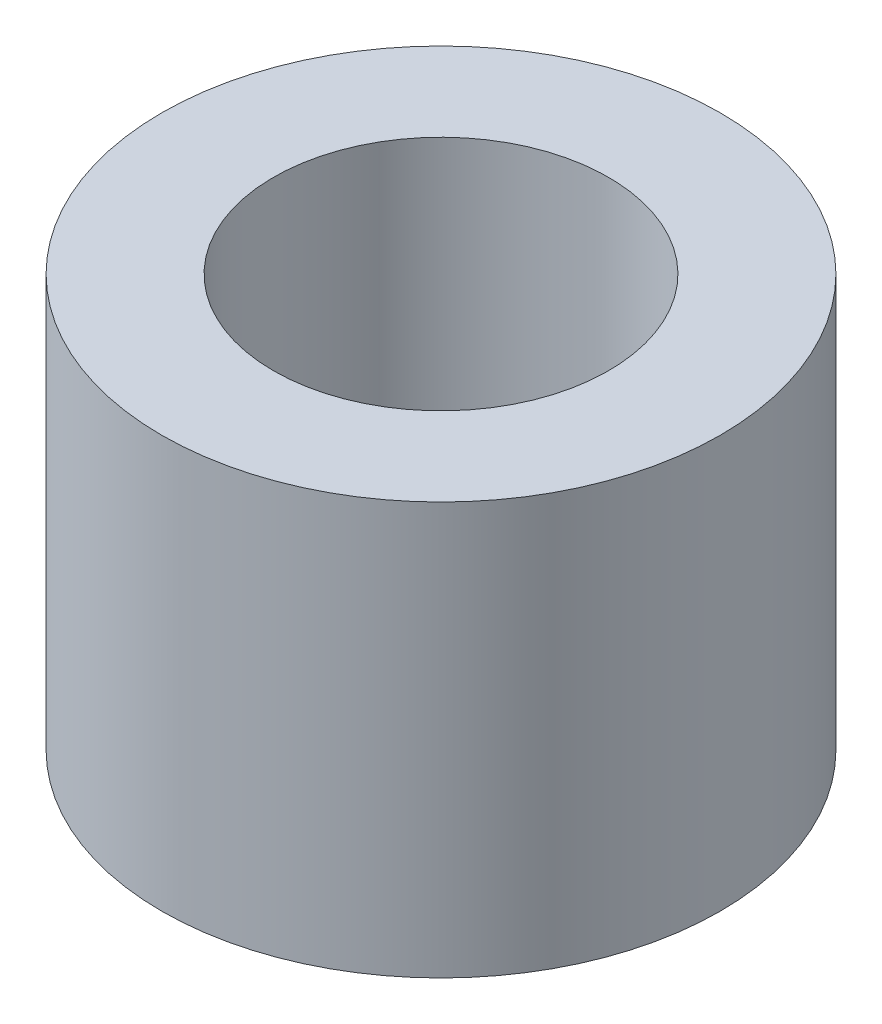
from build123d import *

# Parameters (mm, degrees)
SKETCH1_R           = 5
BOSS_EXTRUDE1_DEPTH = 7.38
SKETCH2_R           = 3
CUT_EXTRUDE1_DEPTH  = 7.38


with BuildPart() as part:
    # Sketch1 → Boss-Extrude1 (new body)
    with BuildSketch(Plane(origin=(0, 0, 0), x_dir=(1, 0, 0), z_dir=(0, 1, 0))):
        Circle(SKETCH1_R)
    extrude(amount=BOSS_EXTRUDE1_DEPTH)

    # Sketch2 → Cut-Extrude1 (cut)
    with BuildSketch(Plane(origin=(0, 7.38, 0), x_dir=(1, 0, 0), z_dir=(0, 1, 0))):
        Circle(SKETCH2_R)
    extrude(amount=-CUT_EXTRUDE1_DEPTH, mode=Mode.SUBTRACT)


solid = part.part
